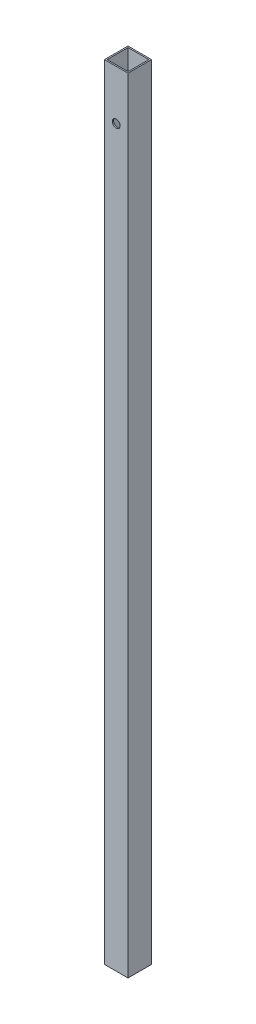
from build123d import *

# Parameters (mm, degrees)
SKETCH1_W           = 18
SKETCH1_H           = 18
SKETCH1_W_2         = 16
SKETCH1_H_2         = 16
BOSS_EXTRUDE1_DEPTH = 600
SKETCH2_R           = 3
CUT_EXTRUDE1_DEPTH  = 993


with BuildPart() as part:
    # Sketch1 → Boss-Extrude1 (new body)
    with BuildSketch(Plane(origin=(0, 0, 0), x_dir=(1, 0, 0), z_dir=(0, 1, 0))):
        Rectangle(SKETCH1_W, SKETCH1_H)
        Rectangle(SKETCH1_W_2, SKETCH1_H_2, mode=Mode.SUBTRACT)
    extrude(amount=BOSS_EXTRUDE1_DEPTH)

    # Sketch2 → Cut-Extrude1 (cut)
    with BuildSketch(Plane.XY.offset(9)):
        with Locations((0, 562)):
            Circle(SKETCH2_R)
    extrude(amount=-CUT_EXTRUDE1_DEPTH, mode=Mode.SUBTRACT)


solid = part.part
